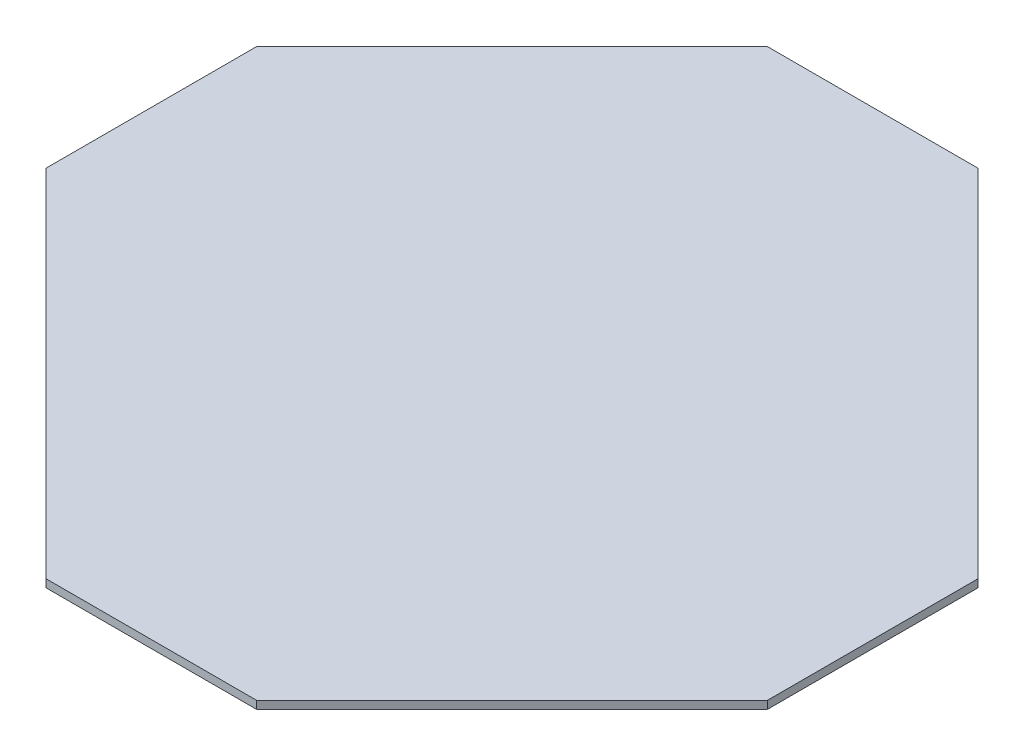
from build123d import *

# Parameters (mm, degrees)
BOSS_EXTRUDE2_DEPTH = 3


with BuildPart() as part:
    # Sketch3 → Boss-Extrude2 (new body)
    with BuildSketch(Plane(origin=(0, 0, 0), x_dir=(1, 0, 0), z_dir=(0, 1, 0))):
        Polygon((146.917568262, 30.566233816), (11.506619665, 165.977182413), (-68.75, 165.977182413), (-165.977182413, 68.75), (-165.977182413, -11.506619665), (-30.566233816, -146.917568262), (49.690385849, -146.917568262), (146.917568262, -49.690385849), align=None)
    extrude(amount=BOSS_EXTRUDE2_DEPTH)


solid = part.part
